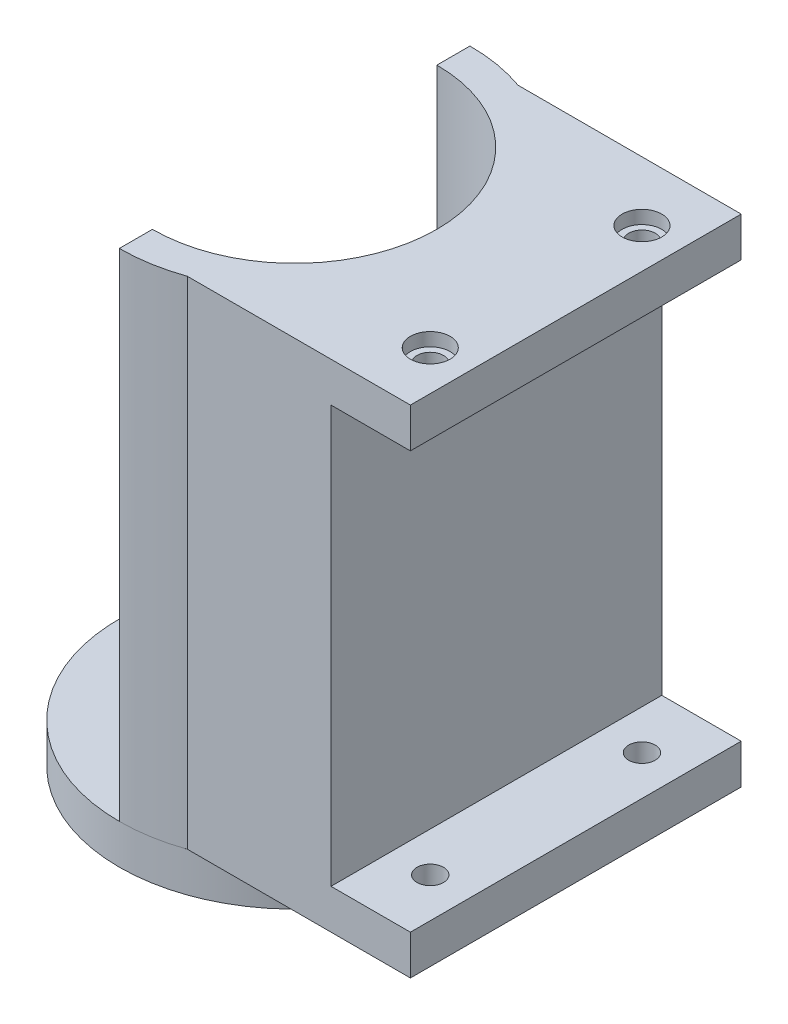
from build123d import *

# Parameters (mm, degrees)
SKETCH1_R                = 13.25
SKETCH1_R_2              = 1
BOSS_EXTRUDE1_DEPTH      = 3
BOSS_EXTRUDE4_DEPTH      = 37.5
BOSS_EXTRUDE5_REACH      = 53.265
BOSS_EXTRUDE5_END_RADIUS = 13.25
SKETCH4_W                = 12.5
SKETCH4_H                = 37.5
SKETCH6_W                = 25
SKETCH6_H                = 3
BOSS_EXTRUDE6_DEPTH      = 6
SKETCH7_R                = 1
CUT_EXTRUDE1_DEPTH       = 48.616961264
SKETCH8_R                = 1.5
CUT_EXTRUDE2_DEPTH       = 1
SKETCH9_R                = 1.5
CUT_EXTRUDE3_DEPTH       = 1


with BuildPart() as part:
    # Sketch1 → Boss-Extrude1 (new body)
    with BuildSketch(Plane(origin=(0, 0, 0), x_dir=(1, 0, 0), z_dir=(0, 1, 0))):
        with Locations(Location((0, 0, 0), (0, 0, 270))):
            Circle(SKETCH1_R)
        with Locations(Location((-8, 0, 0), (0, 0, 270))):
            Circle(SKETCH1_R_2, mode=Mode.SUBTRACT)
        with Locations(Location((0, 8, 0), (0, 0, 270))):
            Circle(SKETCH1_R_2, mode=Mode.SUBTRACT)
        with Locations(Location((8, 0, 0), (0, 0, 270))):
            Circle(SKETCH1_R_2, mode=Mode.SUBTRACT)
        with Locations(Location((0, -8, 0), (0, 0, 270))):
            Circle(SKETCH1_R_2, mode=Mode.SUBTRACT)
    extrude(amount=BOSS_EXTRUDE1_DEPTH)


with BuildPart() as body_2:
    # Sketch2 → Boss-Extrude4 (new body)
    with BuildSketch(Plane(origin=(0, 3, 0), x_dir=(1, 0, 0), z_dir=(0, 1, 0))):
        with BuildLine():
            Line((0, 13.25), (0, 10.75))
            ThreePointArc((0, 10.75), (10.75, 0), (0, -10.75))
            Line((0, -10.75), (0, -13.25))
            ThreePointArc((0, -13.25), (13.25, 0), (0, 13.25))
        make_face()
    extrude(amount=BOSS_EXTRUDE4_DEPTH)

    # Boss-Extrude5: up to this cylinder (the profile starts outside it)
    boss_extrude5_end = Plane(origin=(0, 21.75, 0), z_dir=(0, -1, 0)) * Cylinder(BOSS_EXTRUDE5_END_RADIUS, 134.03, mode=Mode.PRIVATE)
    # Sketch4 → Boss-Extrude5 (add, up to the surface)
    with BuildSketch(Plane(origin=(15.25, 0, 0), x_dir=(0, 0, -1), z_dir=(1, 0, 0)), mode=Mode.PRIVATE) as boss_extrude5_sk1:
        with Locations((-6.25, 21.75)):
            Rectangle(SKETCH4_W, SKETCH4_H)
    boss_extrude5_tool1 = extrude(boss_extrude5_sk1.sketch, amount=-BOSS_EXTRUDE5_REACH, mode=Mode.PRIVATE) - boss_extrude5_end
    add(boss_extrude5_tool1.solids().sort_by_distance((15.25, 21.75, 6.25))[0])
    # Sketch4 → Boss-Extrude5 (add, up to the surface)
    with BuildSketch(Plane(origin=(15.25, 0, 0), x_dir=(0, 0, -1), z_dir=(1, 0, 0)), mode=Mode.PRIVATE) as boss_extrude5_sk2:
        with Locations((6.25, 21.75)):
            Rectangle(SKETCH4_W, SKETCH4_H)
    boss_extrude5_tool2 = extrude(boss_extrude5_sk2.sketch, amount=-BOSS_EXTRUDE5_REACH, mode=Mode.PRIVATE) - boss_extrude5_end
    add(boss_extrude5_tool2.solids().sort_by_distance((15.25, 21.75, -6.25))[0])

    # Sketch6 → Boss-Extrude6 (add)
    with BuildSketch(Plane(origin=(15.25, 0, 0), x_dir=(0, 0, -1), z_dir=(1, 0, 0))):
        with Locations((0, 39)):
            Rectangle(SKETCH6_W, SKETCH6_H)
        with Locations((0, 4.5)):
            Rectangle(SKETCH6_W, SKETCH6_H)
    extrude(amount=BOSS_EXTRUDE6_DEPTH)

    # Sketch7 → Cut-Extrude1 (cut, through all)
    with BuildSketch(Plane(origin=(0, 40.5, 0), x_dir=(1, 0, 0), z_dir=(0, 1, 0))):
        with Locations(Location((18.25, 8, 0), (0, 0, 270))):
            Circle(SKETCH7_R)
        with Locations(Location((18.25, -8, 0), (0, 0, 270))):
            Circle(SKETCH7_R)
    extrude(amount=-CUT_EXTRUDE1_DEPTH, mode=Mode.SUBTRACT)

    # Sketch8 → Cut-Extrude2 (cut)
    with BuildSketch(Plane(origin=(0, 40.5, 0), x_dir=(1, 0, 0), z_dir=(0, 1, 0))):
        with Locations(Location((18.25, 8, 0), (0, 0, 270))):
            Circle(SKETCH8_R)
        with Locations(Location((18.25, -8, 0), (0, 0, 270))):
            Circle(SKETCH8_R)
    extrude(amount=-CUT_EXTRUDE2_DEPTH, mode=Mode.SUBTRACT)

    # Sketch9 → Cut-Extrude3 (cut)
    with BuildSketch(Plane.XZ.offset(-3)):
        with Locations(Location((18.25, 8, 0), (0, 0, 90))):
            Circle(SKETCH9_R)
        with Locations(Location((18.25, -8, 0), (0, 0, 90))):
            Circle(SKETCH9_R)
    extrude(amount=-CUT_EXTRUDE3_DEPTH, mode=Mode.SUBTRACT)


solid = Compound([part.part, body_2.part])
